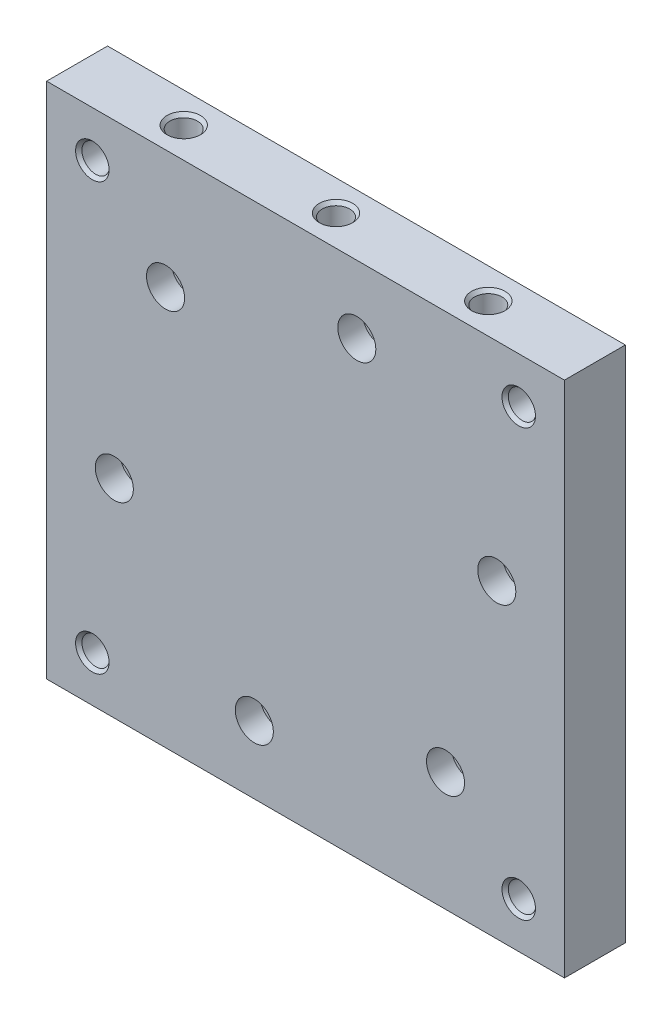
from build123d import *

# Parameters (mm, degrees)
SKETCH1_W                                        = 215.9
SKETCH1_H                                        = 215.9
BOSS_EXTRUDE1_DEPTH                              = 25.4
F_1_2_20_TAPPED_HOLE1_D                          = 11.50874
F_1_2_20_TAPPED_HOLE1_CSINK_D                    = 13.97
F_1_2_20_TAPPED_HOLE1_CSINK_ANGLE                = 82
CBORE_FOR_3_8_SOCKET_HEAD_CAP_SCREW1_D           = 10.3124
CBORE_FOR_3_8_SOCKET_HEAD_CAP_SCREW1_CBORE_D     = 15.875
CBORE_FOR_3_8_SOCKET_HEAD_CAP_SCREW1_CBORE_DEPTH = 10.3124
F_1_2_20_TAPPED_HOLE2_AT_2_COUNT                 = 2
F_1_2_20_TAPPED_HOLE2_AT_2_PITCH                 = 63.5
F_1_2_20_TAPPED_HOLE2_AT_3_COUNT                 = 2
F_1_2_20_TAPPED_HOLE2_AT_3_PITCH                 = 63.5
CIRPATTERN1_COUNT                                = 2
CIRPATTERN1_ANGLE                                = 90


with BuildPart() as part:
    # Sketch1 → Boss-Extrude1 (new body)
    with BuildSketch(Plane.XY):
        Rectangle(SKETCH1_W, SKETCH1_H)
    extrude(amount=BOSS_EXTRUDE1_DEPTH)

    # 1/2-20 Tapped Hole1 (through all)
    with Locations(Plane.XY.offset(25.4)):
        with Locations((-88.9, -88.9), (88.9, 88.9), (-88.9, 88.9), (88.9, -88.9)):
            CounterSinkHole(F_1_2_20_TAPPED_HOLE1_D / 2, F_1_2_20_TAPPED_HOLE1_CSINK_D / 2, counter_sink_angle=F_1_2_20_TAPPED_HOLE1_CSINK_ANGLE)

    # CBORE for 3/8 Socket Head Cap Screw1 (through all)
    with Locations(Plane.XY.offset(25.4)):
        with Locations((-58.371664787, 58.371664787), (-79.73717696, -21.365512173), (-21.365512173, -79.73717696), (58.371664787, -58.371664787), (79.73717696, 21.365512173), (21.365512173, 79.73717696)):
            CounterBoreHole(CBORE_FOR_3_8_SOCKET_HEAD_CAP_SCREW1_D / 2, CBORE_FOR_3_8_SOCKET_HEAD_CAP_SCREW1_CBORE_D / 2, CBORE_FOR_3_8_SOCKET_HEAD_CAP_SCREW1_CBORE_DEPTH)

    # Sketch6 → 1/2-20 Tapped Hole2 (revolve, cut)
    with BuildSketch(Plane(origin=(-107.95, 0, 12.7), x_dir=(0, 0, 1), z_dir=(0, 1, 0))):
        Polygon((0, 0), (0, 23.14257432), (5.75437, 19.685), (5.75437, 1.415677873), (6.985, 0), align=None)
    f_1_2_20_tapped_hole2 = revolve(axis=Axis((-114.3, 0, 12.7), (1, 0, 0)), mode=Mode.SUBTRACT)

    # 1/2-20 Tapped Hole2 at 2: 1/2-20 Tapped Hole2 ×2
    with Locations(*[(0, i * F_1_2_20_TAPPED_HOLE2_AT_2_PITCH, 0) for i in range(1, F_1_2_20_TAPPED_HOLE2_AT_2_COUNT)]):
        add(f_1_2_20_tapped_hole2, mode=Mode.SUBTRACT)

    # 1/2-20 Tapped Hole2 at 3: 1/2-20 Tapped Hole2 ×2
    with Locations(*[(0, -i * F_1_2_20_TAPPED_HOLE2_AT_3_PITCH, 0) for i in range(1, F_1_2_20_TAPPED_HOLE2_AT_3_COUNT)]):
        add(f_1_2_20_tapped_hole2, mode=Mode.SUBTRACT)

    # CirPattern1: 1/2-20 Tapped Hole2 ×2 about axis
    cirpattern1_axis = Axis((0, 0, -1.27), (0, 0, -1))
    for i in range(1, CIRPATTERN1_COUNT):
        add(f_1_2_20_tapped_hole2.rotate(cirpattern1_axis, i * CIRPATTERN1_ANGLE / (CIRPATTERN1_COUNT - 1)), mode=Mode.SUBTRACT)

    # CirPattern1 copy 1 sketch → CirPattern1 copy 1 (revolve, cut)
    with BuildSketch(Plane(origin=(63.5, 107.95, 12.7), x_dir=(0, 0, 1), z_dir=(1, 0, 0))):
        Polygon((0, 0), (0, 23.14257432), (5.75437, 19.685), (5.75437, 1.415677873), (6.985, 0), align=None)
    revolve(axis=Axis((63.5, 114.3, 12.7), (0, -1, 0)), mode=Mode.SUBTRACT)

    # CirPattern1 copy 2 sketch → CirPattern1 copy 2 (revolve, cut)
    with BuildSketch(Plane(origin=(-63.5, 107.95, 12.7), x_dir=(0, 0, 1), z_dir=(1, 0, 0))):
        Polygon((0, 0), (0, 23.14257432), (5.75437, 19.685), (5.75437, 1.415677873), (6.985, 0), align=None)
    revolve(axis=Axis((-63.5, 114.3, 12.7), (0, -1, 0)), mode=Mode.SUBTRACT)


solid = part.part
